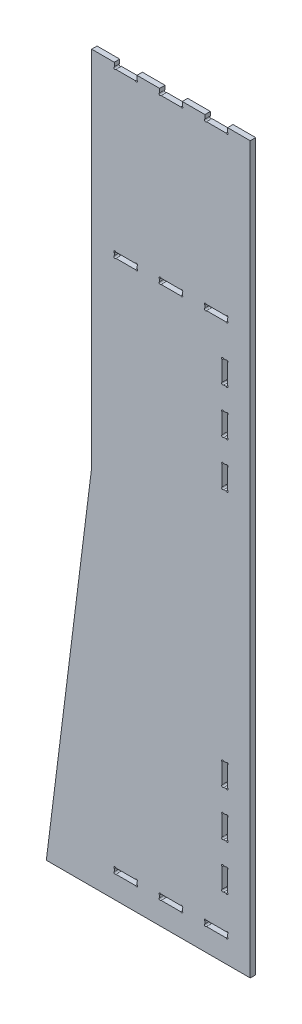
from build123d import *

# Parameters (mm, degrees)
BOSS_EXTRUDE1_DEPTH = 12


with BuildPart() as part:
    # Sketch1 → Boss-Extrude1 (new body)
    with BuildSketch(Plane.XY):
        with BuildLine():
            Line((230.263882669, 423.104693141), (230.263882669, -376.895306859))
            Line((230.263882669, -376.895306859), (-219.736117331, -376.895306859))
            Line((-219.736117331, -376.895306859), (-119.736117331, 423.104693141))
            Line((-119.736117331, 423.104693141), (-119.736117331, 1223.104693141))
            Line((-119.736117331, 1223.104693141), (-69.736117331, 1223.104693141))
            Line((-69.736117331, 1223.104693141), (-69.736117331, 1218.104693141))
            Line((-69.736117331, 1218.104693141), (-69.736117331, 1214.38315411))
            ThreePointArc((-69.736117331, 1214.38315411), (-70.233173605, 1210.607636866), (-66.457656361, 1211.104693141))
            Line((-66.457656361, 1211.104693141), (-23.0145783, 1211.104693141))
            ThreePointArc((-23.0145783, 1211.104693141), (-19.239061056, 1210.607636866), (-19.736117331, 1214.38315411))
            Line((-19.736117331, 1214.38315411), (-19.736117331, 1218.104693141))
            Line((-19.736117331, 1218.104693141), (-19.736117331, 1223.104693141))
            Line((-19.736117331, 1223.104693141), (30.263882669, 1223.104693141))
            Line((30.263882669, 1223.104693141), (30.263882669, 1218.104693141))
            Line((30.263882669, 1218.104693141), (30.263882669, 1214.38315411))
            ThreePointArc((30.263882669, 1214.38315411), (29.766826395, 1210.607636866), (33.542343639, 1211.104693141))
            Line((33.542343639, 1211.104693141), (76.9854217, 1211.104693141))
            ThreePointArc((76.9854217, 1211.104693141), (80.760938944, 1210.607636866), (80.263882669, 1214.38315411))
            Line((80.263882669, 1214.38315411), (80.263882669, 1218.104693141))
            Line((80.263882669, 1218.104693141), (80.263882669, 1223.104693141))
            Line((80.263882669, 1223.104693141), (130.263882669, 1223.104693141))
            Line((130.263882669, 1223.104693141), (130.263882669, 1218.104693141))
            Line((130.263882669, 1218.104693141), (130.263882669, 1214.38315411))
            ThreePointArc((130.263882669, 1214.38315411), (129.766826395, 1210.607636866), (133.542343639, 1211.104693141))
            Line((133.542343639, 1211.104693141), (176.9854217, 1211.104693141))
            ThreePointArc((176.9854217, 1211.104693141), (180.760938944, 1210.607636866), (180.263882669, 1214.38315411))
            Line((180.263882669, 1214.38315411), (180.263882669, 1223.104693141))
            Line((180.263882669, 1223.104693141), (230.263882669, 1223.104693141))
            Line((230.263882669, 1223.104693141), (230.263882669, 423.104693141))
        make_face()
        with BuildLine():
            Line((-66.457391449, 862.104693141), (-23.014843212, 862.104693141))
            ThreePointArc((-23.014843212, 862.104693141), (-19.239248423, 862.602395721), (-19.736117331, 858.82669113))
            Line((-19.736117331, 858.82669113), (-19.736117331, 853.382695152))
            ThreePointArc((-19.736117331, 853.382695152), (-19.239248423, 849.606990561), (-23.014843212, 850.104693141))
            Line((-23.014843212, 850.104693141), (-66.457391449, 850.104693141))
            ThreePointArc((-66.457391449, 850.104693141), (-70.232986238, 849.606990561), (-69.736117331, 853.382695152))
            Line((-69.736117331, 853.382695152), (-69.736117331, 858.82669113))
            ThreePointArc((-69.736117331, 858.82669113), (-70.232986238, 862.602395721), (-66.457391449, 862.104693141))
        make_face(mode=Mode.SUBTRACT)
        with BuildLine():
            Line((33.542343639, 862.104693141), (76.9854217, 862.104693141))
            ThreePointArc((76.9854217, 862.104693141), (80.760938944, 862.601749416), (80.263882669, 858.826232172))
            Line((80.263882669, 858.826232172), (80.263882669, 853.38315411))
            ThreePointArc((80.263882669, 853.38315411), (80.760938944, 849.607636866), (76.9854217, 850.104693141))
            Line((76.9854217, 850.104693141), (33.542343639, 850.104693141))
            ThreePointArc((33.542343639, 850.104693141), (29.766826395, 849.607636866), (30.263882669, 853.38315411))
            Line((30.263882669, 853.38315411), (30.263882669, 858.826232172))
            ThreePointArc((30.263882669, 858.826232172), (29.766826395, 862.601749416), (33.542343639, 862.104693141))
        make_face(mode=Mode.SUBTRACT)
        with BuildLine():
            Line((130.263882669, 858.823377008), (130.263882669, 853.386009273))
            ThreePointArc((130.263882669, 853.386009273), (129.759845585, 849.609661156), (133.537384707, 850.104693141))
            Line((133.537384707, 850.104693141), (176.990380631, 850.104693141))
            ThreePointArc((176.990380631, 850.104693141), (180.767919754, 849.609661156), (180.263882669, 853.386009273))
            Line((180.263882669, 853.386009273), (180.263882669, 858.823377008))
            ThreePointArc((180.263882669, 858.823377008), (180.767919754, 862.599725126), (176.990380631, 862.104693141))
            Line((176.990380631, 862.104693141), (133.537384707, 862.104693141))
            ThreePointArc((133.537384707, 862.104693141), (129.759845585, 862.599725126), (130.263882669, 858.823377008))
        make_face(mode=Mode.SUBTRACT)
        with BuildLine():
            Line((-66.459371529, -326.895306859), (-23.012863132, -326.895306859))
            ThreePointArc((-23.012863132, -326.895306859), (-19.237850179, -327.388185527), (-19.736117331, -323.613880024))
            Line((-19.736117331, -323.613880024), (-19.736117331, -318.176733694))
            ThreePointArc((-19.736117331, -318.176733694), (-19.237850179, -314.402428191), (-23.012863132, -314.895306859))
            Line((-23.012863132, -314.895306859), (-66.459371529, -314.895306859))
            ThreePointArc((-66.459371529, -314.895306859), (-70.234384482, -314.402428191), (-69.736117331, -318.176733694))
            Line((-69.736117331, -318.176733694), (-69.736117331, -323.613880024))
            ThreePointArc((-69.736117331, -323.613880024), (-70.234384482, -327.388185527), (-66.459371529, -326.895306859))
        make_face(mode=Mode.SUBTRACT)
        with BuildLine():
            Line((33.542343639, -326.895306859), (76.9854217, -326.895306859))
            ThreePointArc((76.9854217, -326.895306859), (80.760938944, -327.392363134), (80.263882669, -323.61684589))
            Line((80.263882669, -323.61684589), (80.263882669, -318.173767828))
            ThreePointArc((80.263882669, -318.173767828), (80.760938944, -314.398250584), (76.9854217, -314.895306859))
            Line((76.9854217, -314.895306859), (33.542343639, -314.895306859))
            ThreePointArc((33.542343639, -314.895306859), (29.766826395, -314.398250584), (30.263882669, -318.173767828))
            Line((30.263882669, -318.173767828), (30.263882669, -323.61684589))
            ThreePointArc((30.263882669, -323.61684589), (29.766826395, -327.392363134), (33.542343639, -326.895306859))
        make_face(mode=Mode.SUBTRACT)
        with BuildLine():
            Line((133.541000442, -326.895306859), (176.986764897, -326.895306859))
            ThreePointArc((176.986764897, -326.895306859), (180.762830308, -327.39181479), (180.263882669, -323.616070974))
            Line((180.263882669, -323.616070974), (180.263882669, -318.174542745))
            ThreePointArc((180.263882669, -318.174542745), (180.762830308, -314.398798928), (176.986764897, -314.895306859))
            Line((176.986764897, -314.895306859), (133.541000442, -314.895306859))
            ThreePointArc((133.541000442, -314.895306859), (129.764935031, -314.398798928), (130.263882669, -318.174542745))
            Line((130.263882669, -318.174542745), (130.263882669, -323.616070974))
            ThreePointArc((130.263882669, -323.616070974), (129.764935031, -327.39181479), (133.541000442, -326.895306859))
        make_face(mode=Mode.SUBTRACT)
        with BuildLine():
            Line((171.542343639, 8.166055965), (176.9854217, 8.166055965))
            ThreePointArc((176.9854217, 8.166055965), (180.760938944, 8.66311224), (180.263882669, 4.887594996))
            Line((180.263882669, 4.887594996), (180.263882669, -38.555483066))
            ThreePointArc((180.263882669, -38.555483066), (180.760938944, -42.33100031), (176.9854217, -41.833944035))
            Line((176.9854217, -41.833944035), (171.542343639, -41.833944035))
            ThreePointArc((171.542343639, -41.833944035), (167.766826395, -42.33100031), (168.263882669, -38.555483066))
            Line((168.263882669, -38.555483066), (168.263882669, 4.887594996))
            ThreePointArc((168.263882669, 4.887594996), (167.766826395, 8.66311224), (171.542343639, 8.166055965))
        make_face(mode=Mode.SUBTRACT)
        with BuildLine():
            Line((168.263882669, -95.112405004), (168.263882669, -138.555483066))
            ThreePointArc((168.263882669, -138.555483066), (167.766826395, -142.33100031), (171.542343639, -141.833944035))
            Line((171.542343639, -141.833944035), (176.9854217, -141.833944035))
            ThreePointArc((176.9854217, -141.833944035), (180.760938944, -142.33100031), (180.263882669, -138.555483066))
            Line((180.263882669, -138.555483066), (180.263882669, -95.112405004))
            ThreePointArc((180.263882669, -95.112405004), (180.760938944, -91.33688776), (176.9854217, -91.833944035))
            Line((176.9854217, -91.833944035), (171.542343639, -91.833944035))
            ThreePointArc((171.542343639, -91.833944035), (167.766826395, -91.33688776), (168.263882669, -95.112405004))
        make_face(mode=Mode.SUBTRACT)
        with BuildLine():
            Line((171.542343639, -191.833944035), (176.9854217, -191.833944035))
            ThreePointArc((176.9854217, -191.833944035), (180.760938944, -191.33688776), (180.263882669, -195.112405004))
            Line((180.263882669, -195.112405004), (180.263882669, -238.555483066))
            ThreePointArc((180.263882669, -238.555483066), (180.760938944, -242.33100031), (176.9854217, -241.833944035))
            Line((176.9854217, -241.833944035), (171.542343639, -241.833944035))
            ThreePointArc((171.542343639, -241.833944035), (167.766826395, -242.33100031), (168.263882669, -238.555483066))
            Line((168.263882669, -238.555483066), (168.263882669, -195.112405004))
            ThreePointArc((168.263882669, -195.112405004), (167.766826395, -191.33688776), (171.542343639, -191.833944035))
        make_face(mode=Mode.SUBTRACT)
        with BuildLine():
            Line((168.263882669, 730.321791286), (168.263882669, 773.764869348))
            ThreePointArc((168.263882669, 773.764869348), (167.766826395, 777.540386592), (171.542343639, 777.043330317))
            Line((171.542343639, 777.043330317), (176.9854217, 777.043330317))
            ThreePointArc((176.9854217, 777.043330317), (180.760938944, 777.540386592), (180.263882669, 773.764869348))
            Line((180.263882669, 773.764869348), (180.263882669, 730.321791286))
            ThreePointArc((180.263882669, 730.321791286), (180.760938944, 726.546274042), (176.9854217, 727.043330317))
            Line((176.9854217, 727.043330317), (171.542343639, 727.043330317))
            ThreePointArc((171.542343639, 727.043330317), (167.766826395, 726.546274042), (168.263882669, 730.321791286))
        make_face(mode=Mode.SUBTRACT)
        with BuildLine():
            Line((171.542343639, 627.043330317), (176.9854217, 627.043330317))
            ThreePointArc((176.9854217, 627.043330317), (180.760938944, 626.546274042), (180.263882669, 630.321791286))
            Line((180.263882669, 630.321791286), (180.263882669, 673.764869348))
            ThreePointArc((180.263882669, 673.764869348), (180.760938944, 677.540386592), (176.9854217, 677.043330317))
            Line((176.9854217, 677.043330317), (171.542343639, 677.043330317))
            ThreePointArc((171.542343639, 677.043330317), (167.766826395, 677.540386592), (168.263882669, 673.764869348))
            Line((168.263882669, 673.764869348), (168.263882669, 630.321791286))
            ThreePointArc((168.263882669, 630.321791286), (167.766826395, 626.546274042), (171.542343639, 627.043330317))
        make_face(mode=Mode.SUBTRACT)
        with BuildLine():
            Line((168.263882669, 530.321791286), (168.263882669, 573.764869348))
            ThreePointArc((168.263882669, 573.764869348), (167.766826395, 577.540386592), (171.542343639, 577.043330317))
            Line((171.542343639, 577.043330317), (176.9854217, 577.043330317))
            ThreePointArc((176.9854217, 577.043330317), (180.760938944, 577.540386592), (180.263882669, 573.764869348))
            Line((180.263882669, 573.764869348), (180.263882669, 530.321791286))
            ThreePointArc((180.263882669, 530.321791286), (180.760938944, 526.546274042), (176.9854217, 527.043330317))
            Line((176.9854217, 527.043330317), (171.542343639, 527.043330317))
            ThreePointArc((171.542343639, 527.043330317), (167.766826395, 526.546274042), (168.263882669, 530.321791286))
        make_face(mode=Mode.SUBTRACT)
    extrude(amount=BOSS_EXTRUDE1_DEPTH)


solid = part.part
